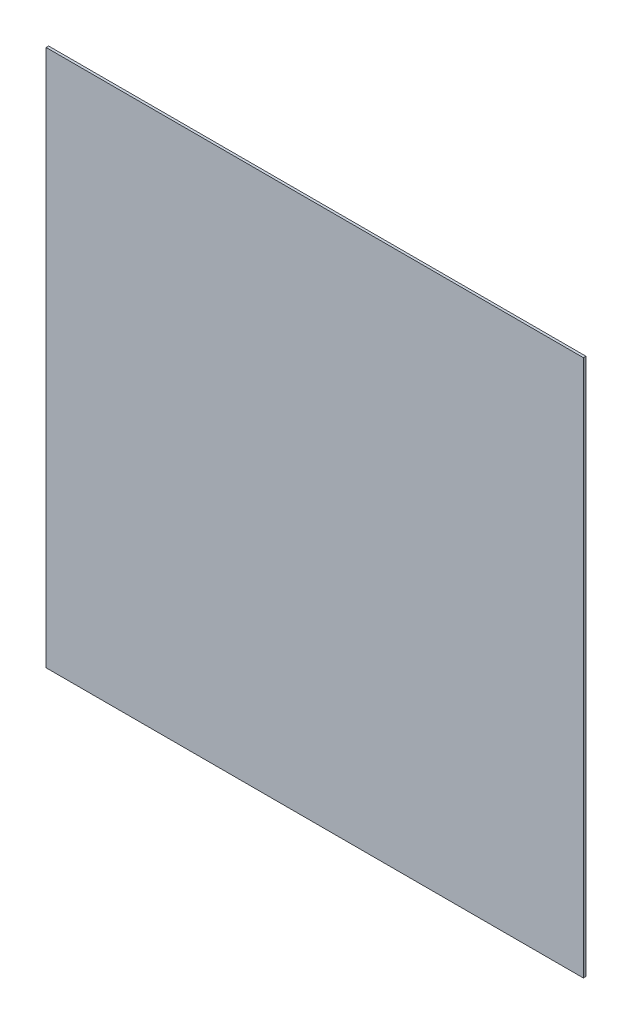
from build123d import *

# Parameters (mm, degrees)
SKETCH_1_W      = 635
SKETCH_1_H      = 635
EXTRUDE_1_DEPTH = 3


with BuildPart() as part:
    # 스케치1 → 보스-돌출1 (new body)
    with BuildSketch(Plane.XY):
        with Locations((317.5, -317.5)):
            Rectangle(SKETCH_1_W, SKETCH_1_H)
    extrude(amount=EXTRUDE_1_DEPTH)


solid = part.part
